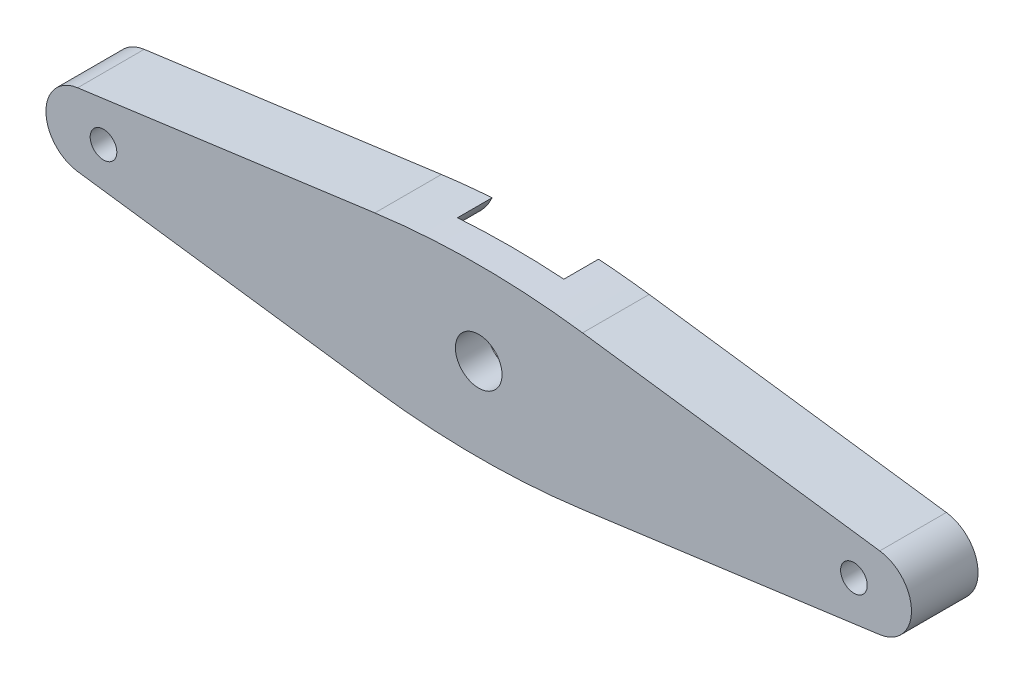
from build123d import *

# Parameters (mm, degrees)
SCHIZZO5_R                   = 1.75
ESTRUSIONE_ESTRUSIONE3_DEPTH = 5
SCHIZZO1_R                   = 1.75
TAGLIO_ESTRUSIONE3_DEPTH     = 2.6
SCHIZZO6_R                   = 1
TAGLIO_ESTRUSIONE4_DEPTH     = 10


with BuildPart() as part:
    # Schizzo5 → Estrusione-Estrusione3 (new body)
    with BuildSketch(Plane.XY):
        with BuildLine():
            Line((-12.11870493, -2.725170944), (10.199561172, -5.744744727))
            ThreePointArc((10.199561172, -5.744744727), (18, -6.270036134), (25.800438828, -5.744744727))
            Line((25.800438828, -5.744744727), (48.11870493, -2.725170944))
            ThreePointArc((48.11870493, -2.725170944), (50.5, 0), (48.11870493, 2.725170944))
            Line((48.11870493, 2.725170944), (25.800438828, 5.744744727))
            ThreePointArc((25.800438828, 5.744744727), (18, 6.270036134), (10.199561172, 5.744744727))
            Line((10.199561172, 5.744744727), (-12.11870493, 2.725170944))
            ThreePointArc((-12.11870493, 2.725170944), (-14.5, 0), (-12.11870493, -2.725170944))
        make_face()
        with Locations((18, 0)):
            Circle(SCHIZZO5_R, mode=Mode.SUBTRACT)
    extrude(amount=ESTRUSIONE_ESTRUSIONE3_DEPTH)

    # Schizzo1 → Taglio-Estrusione3 (cut)
    with BuildSketch(Plane.XY):
        with BuildLine():
            Line((24.948441202, 3.734278154), (34.608428908, 1.712900674))
            ThreePointArc((34.608428908, 1.712900674), (36, 0), (34.608428908, -1.712900674))
            Line((34.608428908, -1.712900674), (24.948441202, -3.734278154))
            ThreePointArc((24.948441202, -3.734278154), (22.862554311, -4.862554311), (21.734278154, -6.948441202))
            Line((21.734278154, -6.948441202), (19.712900674, -16.608428908))
            ThreePointArc((19.712900674, -16.608428908), (18, -18), (16.287099326, -16.608428908))
            Line((16.287099326, -16.608428908), (14.265721846, -6.948441202))
            ThreePointArc((14.265721846, -6.948441202), (13.137445689, -4.862554311), (11.051558798, -3.734278154))
            Line((11.051558798, -3.734278154), (1.391571092, -1.712900674))
            ThreePointArc((1.391571092, -1.712900674), (0, 0), (1.391571092, 1.712900674))
            Line((1.391571092, 1.712900674), (11.051558798, 3.734278154))
            ThreePointArc((11.051558798, 3.734278154), (13.137445689, 4.862554311), (14.265721846, 6.948441202))
            Line((14.265721846, 6.948441202), (16.287099326, 16.608428908))
            ThreePointArc((16.287099326, 16.608428908), (18, 18), (19.712900674, 16.608428908))
            Line((19.712900674, 16.608428908), (21.734278154, 6.948441202))
            ThreePointArc((21.734278154, 6.948441202), (22.862554311, 4.862554311), (24.948441202, 3.734278154))
        make_face()
        with Locations((18, 0)):
            Circle(SCHIZZO1_R, mode=Mode.SUBTRACT)
    extrude(amount=TAGLIO_ESTRUSIONE3_DEPTH, mode=Mode.SUBTRACT)

    # Schizzo6 → Taglio-Estrusione4 (cut)
    with BuildSketch(Plane.XY.offset(5)):
        with Locations((-10.176984684, 0)):
            Circle(SCHIZZO6_R)
        with Locations((46.176984684, 0)):
            Circle(SCHIZZO6_R)
    extrude(amount=-TAGLIO_ESTRUSIONE4_DEPTH, mode=Mode.SUBTRACT)


solid = part.part
